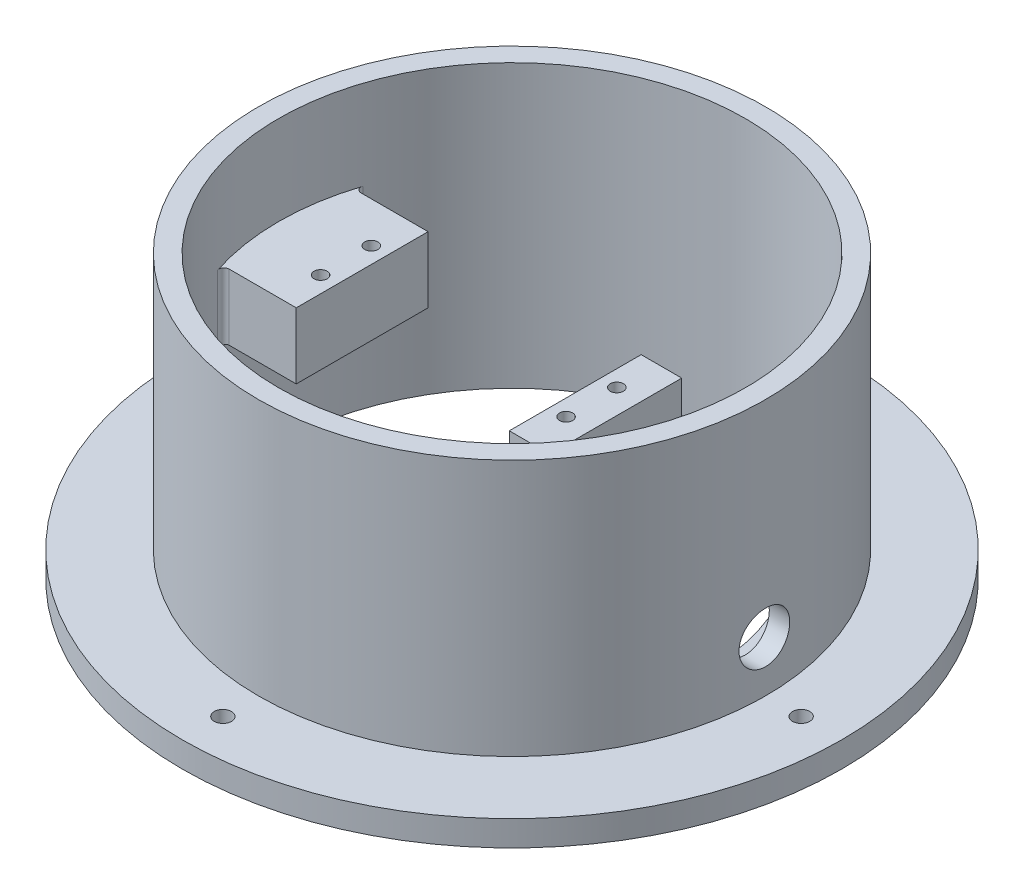
from build123d import *

# Parameters (mm, degrees)
SKETCH1_R               = 65
SKETCH1_R_2             = 46
SKETCH1_R_3             = 1.7
BOSS_EXTRUDE1_DEPTH     = 5
SKETCH3_R               = 50
SKETCH3_R_2             = 46
BOSS_EXTRUDE2_DEPTH     = 50.6
BOSS_EXTRUDE3_DEPTH     = 4
BOSS_EXTRUDE4_DEPTH     = 8
BOSS_EXTRUDE5_DEPTH     = 38
CUT_EXTRUDE3_REACH      = 145.323
CUT_EXTRUDE3_END_RADIUS = 46
SKETCH12_R              = 5
SKETCH13_W              = 42
SKETCH13_H              = 26
CUT_EXTRUDE4_DEPTH      = 38
SKETCH14_R              = 1.3
CUT_EXTRUDE5_DEPTH      = 7.5
CUT_EXTRUDE6_DEPTH      = 25
FILLET1_R               = 1


with BuildPart() as part:
    # Sketch1 → Boss-Extrude1 (new body)
    with BuildSketch(Plane(origin=(0, 0, 0), x_dir=(1, 0, 0), z_dir=(0, 1, 0))):
        with Locations(Location((0, 0, 0), (0, 0, 270))):
            Circle(SKETCH1_R)
        with Locations(Location((0, 0, 0), (0, 0, 270))):
            Circle(SKETCH1_R_2, mode=Mode.SUBTRACT)
        with Locations(Location((0, -57, 0), (0, 0, 270))):
            Circle(SKETCH1_R_3, mode=Mode.SUBTRACT)
        with Locations(Location((-57, 0, 0), (0, 0, 270))):
            Circle(SKETCH1_R_3, mode=Mode.SUBTRACT)
        with Locations(Location((0, 57, 0), (0, 0, 270))):
            Circle(SKETCH1_R_3, mode=Mode.SUBTRACT)
        with Locations(Location((57, 0, 0), (0, 0, 270))):
            Circle(SKETCH1_R_3, mode=Mode.SUBTRACT)
    extrude(amount=BOSS_EXTRUDE1_DEPTH)

    # Sketch3 → Boss-Extrude2 (add)
    with BuildSketch(Plane(origin=(0, 5, 0), x_dir=(1, 0, 0), z_dir=(0, 1, 0))):
        with Locations(Location((0, 0, 0), (0, 0, 270))):
            Circle(SKETCH3_R)
        with Locations(Location((0, 0, 0), (0, 0, 270))):
            Circle(SKETCH3_R_2, mode=Mode.SUBTRACT)
    extrude(amount=BOSS_EXTRUDE2_DEPTH)

    # Sketch4 → Boss-Extrude3 (add)
    with BuildSketch(Plane.XZ):
        with BuildLine():
            Line((30.98386677, -34), (12.463607592, -13))
            Line((12.463607592, -13), (12.463607592, 13))
            Line((12.463607592, 13), (30.98386677, 34))
            ThreePointArc((30.98386677, 34), (46, 0), (30.98386677, -34))
        make_face()
        with BuildLine():
            Line((24.463607592, 16), (30.98386677, 23.393278972))
            ThreePointArc((30.98386677, 23.393278972), (38.823259794, 0), (30.98386677, -23.393278972))
            Line((30.98386677, -23.393278972), (24.463607592, -16))
            Line((24.463607592, -16), (24.463607592, 16))
        make_face(mode=Mode.SUBTRACT)
    extrude(amount=-BOSS_EXTRUDE3_DEPTH)

    # Sketch6 → Boss-Extrude4 (add)
    with BuildSketch(Plane.ZY.offset(-12.463607592)):
        Polygon((13, 4), (13, 38), (-13, 38), (-13, 4), (-5, 4), (-5, 28), (5, 28), (5, 4), align=None)
    extrude(amount=-BOSS_EXTRUDE4_DEPTH)

    # Sketch7 → Boss-Extrude5 (add)
    with BuildSketch(Plane.XZ):
        with BuildLine():
            Line((-44.124822946, 13), (12.463607592, 13))
            Line((12.463607592, 13), (12.463607592, -13))
            Line((12.463607592, -13), (-44.124822946, -13))
            ThreePointArc((-44.124822946, -13), (-46, 0), (-44.124822946, 13))
        make_face()
    extrude(amount=-BOSS_EXTRUDE5_DEPTH)

    # Cut-Extrude3: up to this cylinder (the profile starts outside it)
    cut_extrude3_end = Plane(origin=(0, 15, 0), z_dir=(0, -1, 0)) * Cylinder(CUT_EXTRUDE3_END_RADIUS, 383.646, mode=Mode.PRIVATE)
    # Sketch12 → Cut-Extrude3 (cut, up to the surface)
    with BuildSketch(Plane(origin=(50, 0, 0), x_dir=(0, 0, -1), z_dir=(1, 0, 0)), mode=Mode.PRIVATE) as cut_extrude3_sk1:
        with Locations((0, 15)):
            Circle(SKETCH12_R)
    cut_extrude3_tool1 = extrude(cut_extrude3_sk1.sketch, amount=-CUT_EXTRUDE3_REACH, mode=Mode.PRIVATE) - cut_extrude3_end
    add(cut_extrude3_tool1.solids().sort_by_distance((50, 15, 0))[0], mode=Mode.SUBTRACT)

    # Sketch13 → Cut-Extrude4 (cut)
    with BuildSketch(Plane(origin=(0, 38, 0), x_dir=(1, 0, 0), z_dir=(0, 1, 0))):
        with Locations((-8.536392408, 0)):
            Rectangle(SKETCH13_W, SKETCH13_H)
    extrude(amount=-CUT_EXTRUDE4_DEPTH, mode=Mode.SUBTRACT)

    # Sketch14 → Cut-Extrude5 (cut)
    with BuildSketch(Plane(origin=(0, 38, 0), x_dir=(1, 0, 0), z_dir=(0, 1, 0))):
        with Locations(Location((15.663607592, 5, 0), (0, 0, 270))):
            Circle(SKETCH14_R)
        with Locations(Location((15.663607592, -5, 0), (0, 0, 270))):
            Circle(SKETCH14_R)
        with Locations(Location((-32.736392408, 5, 0), (0, 0, 270))):
            Circle(SKETCH14_R)
        with Locations(Location((-32.736392408, -5, 0), (0, 0, 270))):
            Circle(SKETCH14_R)
    extrude(amount=-CUT_EXTRUDE5_DEPTH, mode=Mode.SUBTRACT)

    # Sketch15 → Cut-Extrude6 (cut)
    with BuildSketch(Plane.XZ):
        with BuildLine():
            Line((-44.124822946, 13), (-29.536392408, 13))
            Line((-29.536392408, 13), (-29.536392408, -13))
            Line((-29.536392408, -13), (-44.124822946, -13))
            ThreePointArc((-44.124822946, -13), (-46, 0), (-44.124822946, 13))
        make_face()
    extrude(amount=-CUT_EXTRUDE6_DEPTH, mode=Mode.SUBTRACT)

    # Fillet1
    fillet1_edges = [part.edges().sort_by_distance(p)[0] for p in [
        (-46, 25, 0),
        (20.463607592, 4, -9),
        (16.463607592, 4, -5),
        (16.463607592, 4, -13),
        (20.463607592, 4, 9),
        (16.463607592, 4, 13),
        (16.463607592, 4, 5),
        (-44.124822946, 31.5, 13),
        (-44.124822946, 31.5, -13),
    ]]
    fillet(fillet1_edges, radius=FILLET1_R)


solid = part.part
